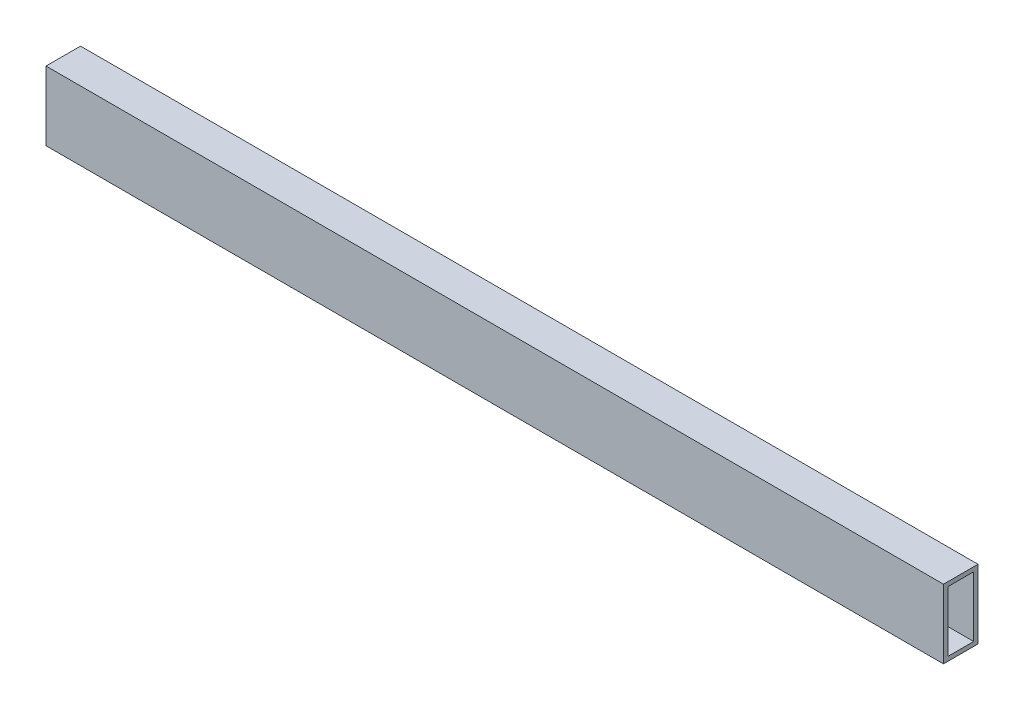
from build123d import *

# Parameters (mm, degrees)
SKETCH1_W           = 660.4
SKETCH1_H           = 25.4
BOSS_EXTRUDE1_DEPTH = 25.4
SHELL1_T            = -3.175


with BuildPart() as part:
    # Sketch1 → Boss-Extrude1 (new body, symmetric)
    with BuildSketch(Plane(origin=(0, 0, 0), x_dir=(1, 0, 0), z_dir=(0, 1, 0))):
        Rectangle(SKETCH1_W, SKETCH1_H)
    extrude(amount=BOSS_EXTRUDE1_DEPTH, both=True)

    # Shell1
    shell1_openings = [part.faces().sort_by_distance(p)[0] for p in [
        (-330.2, 0, 0),
        (330.2, 0, 0),
    ]]
    offset(amount=SHELL1_T, openings=shell1_openings, kind=Kind.INTERSECTION)


solid = part.part
